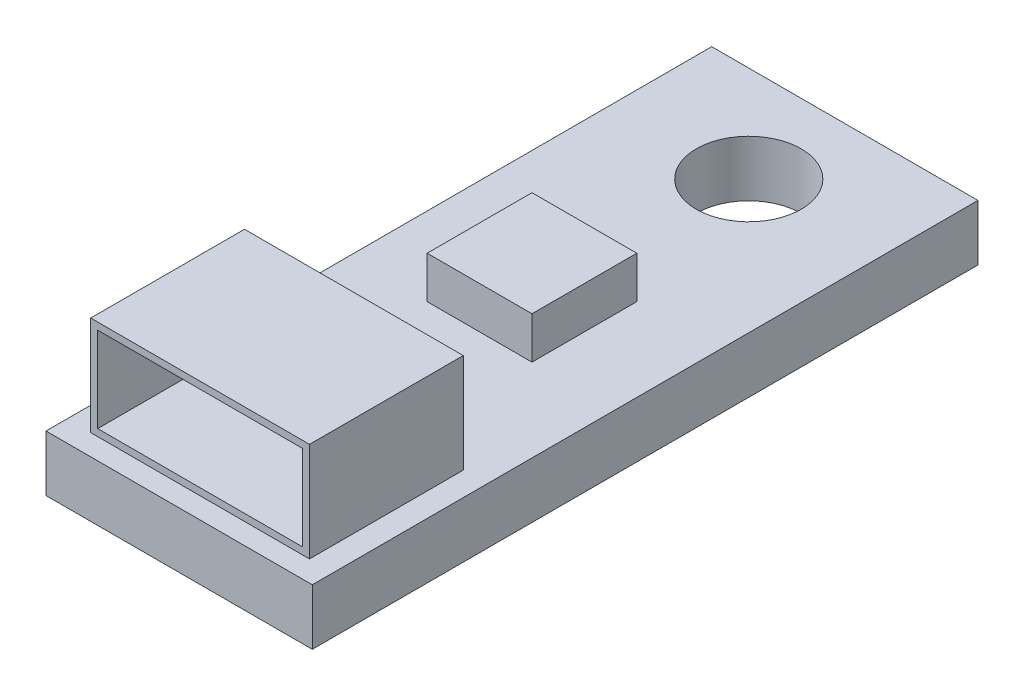
from build123d import *

# Parameters (mm, degrees)
SKETCH1_W           = 7.62
SKETCH1_H           = 19.05
SKETCH1_R           = 1.5
BOSS_EXTRUDE1_DEPTH = 1.6
SKETCH2_W           = 3
SKETCH2_H           = 3
BOSS_EXTRUDE2_DEPTH = 1.2
SKETCH3_W           = 6.26
SKETCH3_H           = 4.4
BOSS_EXTRUDE3_DEPTH = 2.84
SKETCH4_W           = 5.86
SKETCH4_H           = 2.44
CUT_EXTRUDE1_DEPTH  = 4.2


with BuildPart() as part:
    # Sketch1 → Boss-Extrude1 (new body)
    with BuildSketch(Plane(origin=(0, 0, 0), x_dir=(1, 0, 0), z_dir=(0, 1, 0))):
        with Locations((3.81, 9.525)):
            Rectangle(SKETCH1_W, SKETCH1_H)
        with Locations((3.81, 16.3)):
            Circle(SKETCH1_R, mode=Mode.SUBTRACT)
    extrude(amount=BOSS_EXTRUDE1_DEPTH)


with BuildPart() as body_2:
    # Sketch2 → Boss-Extrude2 (new body)
    with BuildSketch(Plane(origin=(0, 1.6, 0), x_dir=(1, 0, 0), z_dir=(0, 1, 0))):
        with Locations((3.746662363, 10.16)):
            Rectangle(SKETCH2_W, SKETCH2_H)
    extrude(amount=BOSS_EXTRUDE2_DEPTH)


with BuildPart() as body_3:
    # Sketch3 → Boss-Extrude3 (new body)
    with BuildSketch(Plane(origin=(0, 1.6, 0), x_dir=(1, 0, 0), z_dir=(0, 1, 0))):
        with Locations((3.81, 2.8)):
            Rectangle(SKETCH3_W, SKETCH3_H)
    extrude(amount=BOSS_EXTRUDE3_DEPTH)

    # Sketch4 → Cut-Extrude1 (cut)
    with BuildSketch(Plane.XY.offset(-0.6)):
        with Locations((3.81, 3.02)):
            Rectangle(SKETCH4_W, SKETCH4_H)
    extrude(amount=-CUT_EXTRUDE1_DEPTH, mode=Mode.SUBTRACT)


solid = Compound([part.part, body_2.part, body_3.part])
